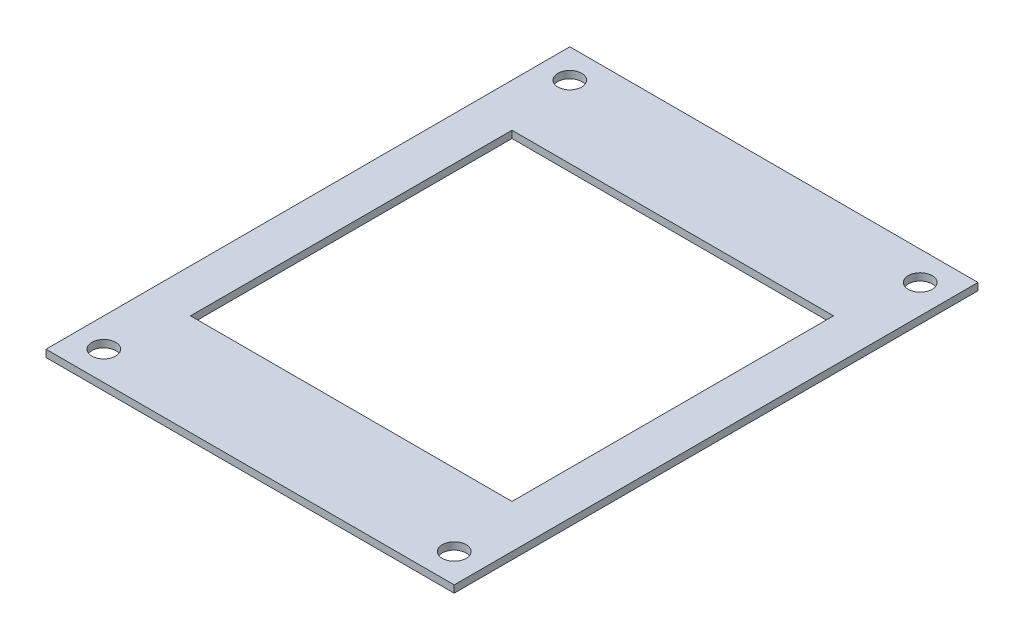
from build123d import *

# Parameters (mm, degrees)
SKETCH1_W           = 56.5
SKETCH1_H           = 72.5
SKETCH1_R           = 1.65
SKETCH1_W_2         = 44.5
SKETCH1_H_2         = 44.5
BOSS_EXTRUDE1_DEPTH = 1


with BuildPart() as part:
    # Sketch1 → Boss-Extrude1 (new body)
    with BuildSketch(Plane(origin=(0, 0, 0), x_dir=(1, 0, 0), z_dir=(0, 1, 0))):
        Rectangle(SKETCH1_W, SKETCH1_H)
        with Locations((-24.25, 32.25)):
            Circle(SKETCH1_R, mode=Mode.SUBTRACT)
        with Locations((24.25, 32.25)):
            Circle(SKETCH1_R, mode=Mode.SUBTRACT)
        with Locations((24.25, -32.25)):
            Circle(SKETCH1_R, mode=Mode.SUBTRACT)
        with Locations((-24.25, -32.25)):
            Circle(SKETCH1_R, mode=Mode.SUBTRACT)
        Rectangle(SKETCH1_W_2, SKETCH1_H_2, mode=Mode.SUBTRACT)
    extrude(amount=BOSS_EXTRUDE1_DEPTH)


solid = part.part
